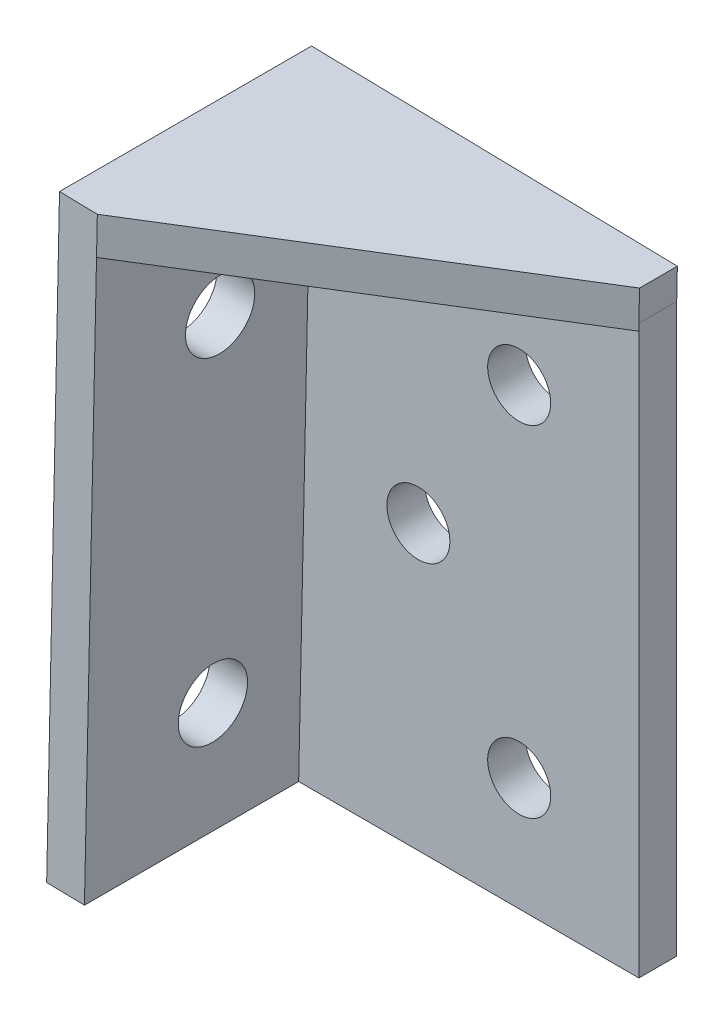
from build123d import *

# Parameters (mm, degrees)
SKETCH1_R           = 2.5
BOSS_EXTRUDE1_DEPTH = 3
SKETCH2_W           = 20
SKETCH2_H           = 45.01020326
SKETCH2_R           = 2.75
BOSS_EXTRUDE2_DEPTH = 3
BOSS_EXTRUDE3_DEPTH = 3


with BuildPart() as part:
    # Sketch1 → Boss-Extrude1 (new body)
    with BuildSketch(Plane.XY):
        Polygon((0, 0), (0.958330597, 45), (27, 45), (27, 0), align=None)
        with Locations((17.5, 36)):
            Circle(SKETCH1_R, mode=Mode.SUBTRACT)
        with Locations((17.5, 9)):
            Circle(SKETCH1_R, mode=Mode.SUBTRACT)
        with Locations((9.5, 22.5)):
            Circle(SKETCH1_R, mode=Mode.SUBTRACT)
    extrude(amount=BOSS_EXTRUDE1_DEPTH)

    # Sketch2 → Boss-Extrude2 (add)
    with BuildSketch(Plane(origin=(0, 0, 0), x_dir=(0, 0, 1), z_dir=(-0.999773312, 0.021291408, 0))):
        with Locations((10, 22.50510163)):
            Rectangle(SKETCH2_W, SKETCH2_H)
        with Locations((10, 36.01020326)):
            Circle(SKETCH2_R, mode=Mode.SUBTRACT)
        with Locations((10, 9)):
            Circle(SKETCH2_R, mode=Mode.SUBTRACT)
    extrude(amount=BOSS_EXTRUDE2_DEPTH)

    # Sketch3 → Boss-Extrude3 (add)
    with BuildSketch(Plane(origin=(0.958330597, 45, 0), x_dir=(0.999773312, -0.021291408, 0), z_dir=(0.021291408, 0.999773312, 0))):
        Polygon((0, -20), (26.035766076, -3), (26.035766076, 0), (-3, 0), (-3, -20), align=None)
    extrude(amount=BOSS_EXTRUDE3_DEPTH)


solid = part.part
